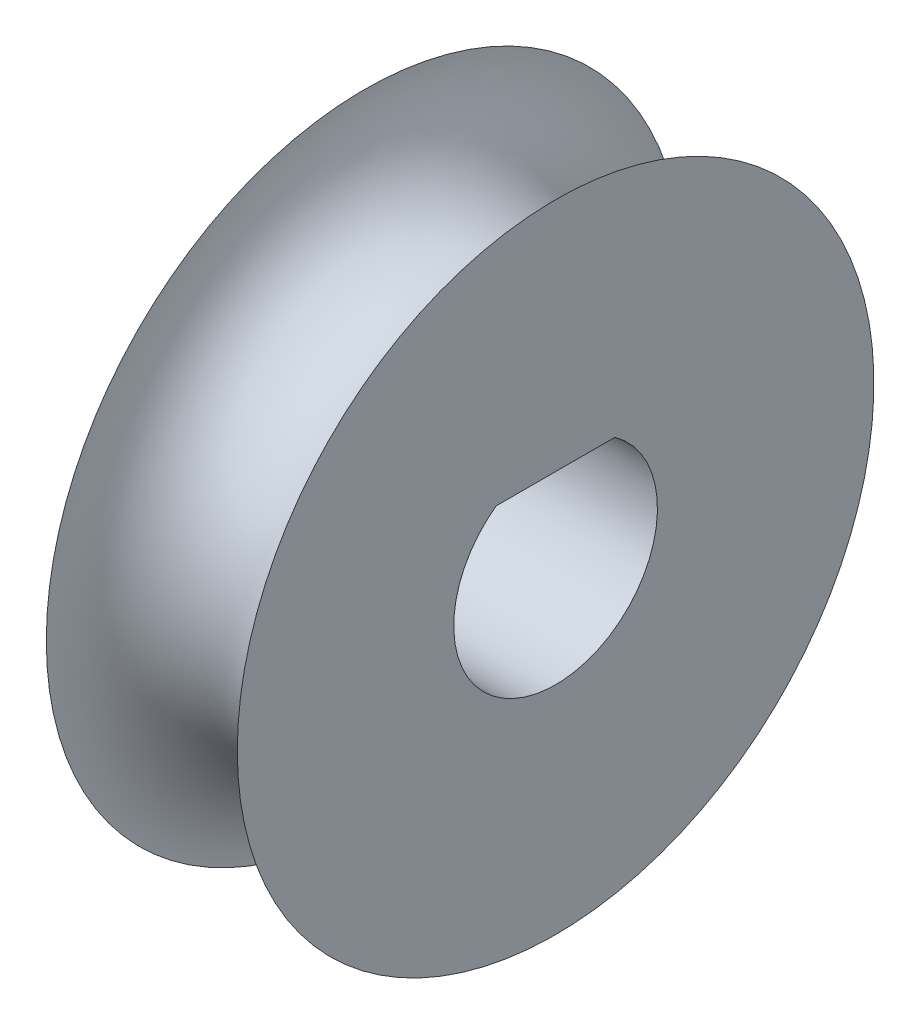
from build123d import *

# Parameters (mm, degrees)
CUT_EXTRUDE1_DEPTH = 8.62


with BuildPart() as part:
    # Sketch1 → Revolve1 (revolve)
    with BuildSketch(Plane.XY):
        with BuildLine():
            Line((-3.81, 12.7), (-3.81, 0))
            Line((-3.81, 0), (3.81, 0))
            Line((3.81, 0), (3.81, 12.7))
            ThreePointArc((3.81, 12.7), (0, 8.890000116), (-3.81, 12.7))
        make_face()
    revolve(axis=Axis((-3.81, 0, 0), (1, 0, 0)))

    # Sketch2 → Cut-Extrude1 (cut, through all)
    with BuildSketch(Plane(origin=(3.81, 0, 0), x_dir=(0, 0, -1), z_dir=(1, 0, 0))):
        with BuildLine():
            Line((-2.369154279, 3.302), (2.369154279, 3.302))
            ThreePointArc((2.369154279, 3.302), (0, -4.064), (-2.369154279, 3.302))
        make_face()
    extrude(amount=-CUT_EXTRUDE1_DEPTH, mode=Mode.SUBTRACT)


solid = part.part
